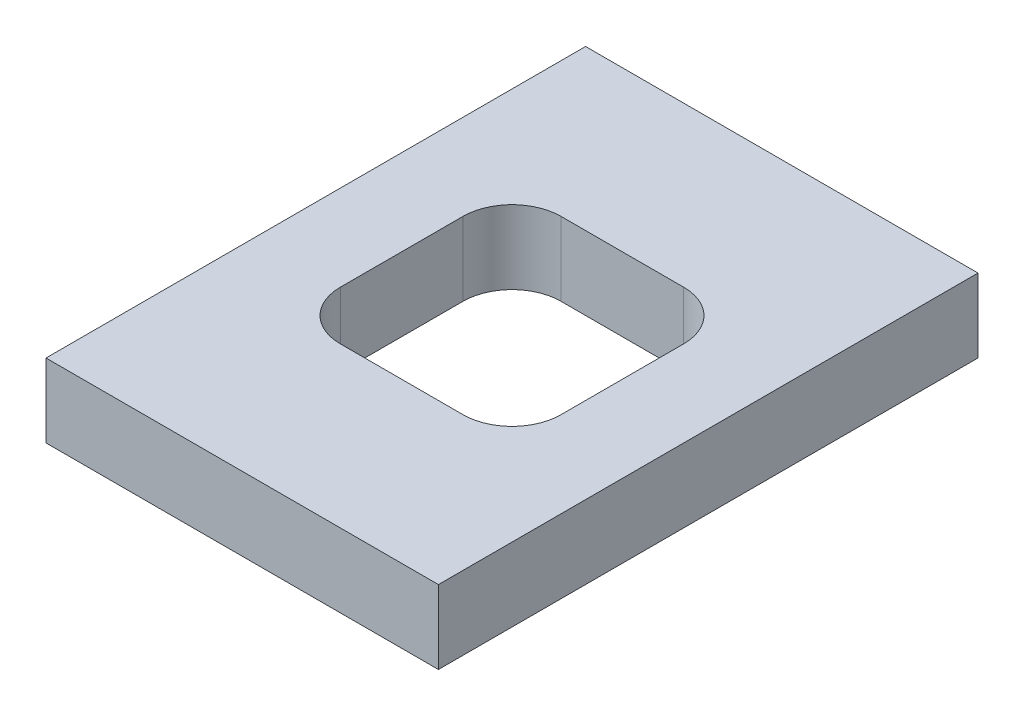
from build123d import *

# Parameters (mm, degrees)
SKETCH1_W           = 16
SKETCH1_H           = 22
SKETCH1_W_2         = 9
SKETCH1_H_2         = 9
BOSS_EXTRUDE1_DEPTH = 1.5
FILLET1_R           = 2


with BuildPart() as part:
    # Sketch1 → Boss-Extrude1 (new body, symmetric)
    with BuildSketch(Plane(origin=(0, 0, 0), x_dir=(1, 0, 0), z_dir=(0, 1, 0))):
        Rectangle(SKETCH1_W, SKETCH1_H)
        Rectangle(SKETCH1_W_2, SKETCH1_H_2, mode=Mode.SUBTRACT)
    extrude(amount=BOSS_EXTRUDE1_DEPTH, both=True)

    # Fillet1
    fillet1_edges = [part.edges().sort_by_distance(p)[0] for p in [
        (-4.5, 0, -4.5),
        (-4.5, 0, 4.5),
        (4.5, 0, 4.5),
        (4.5, 0, -4.5),
    ]]
    fillet(fillet1_edges, radius=FILLET1_R)


solid = part.part
